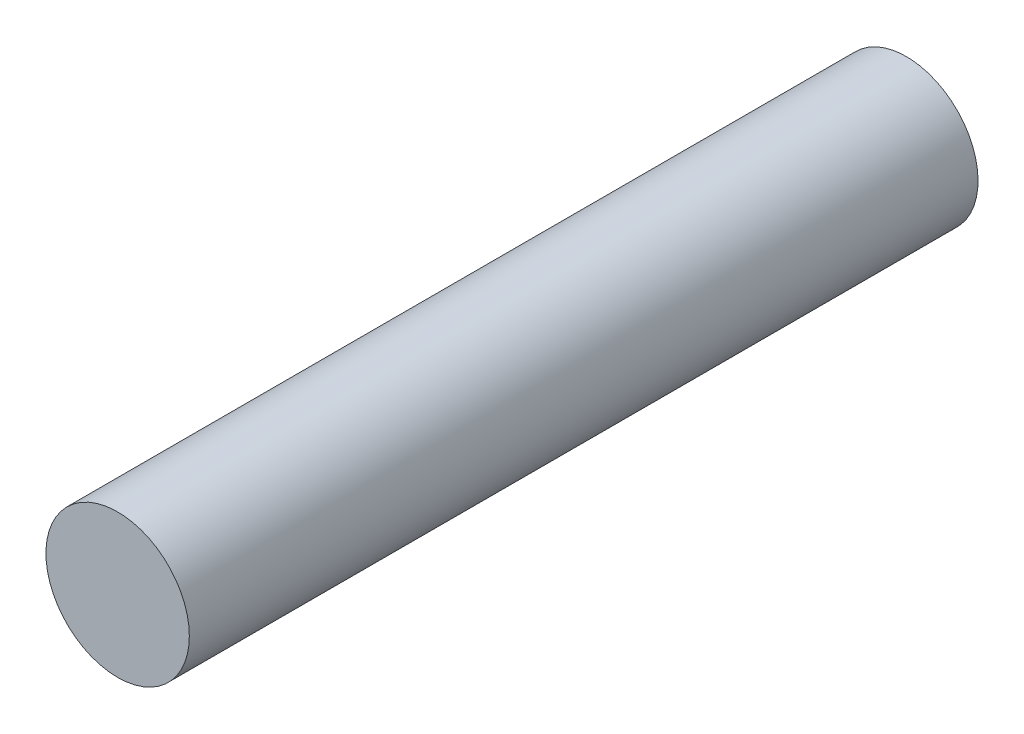
from build123d import *

# Parameters (mm, degrees)
SKETCH_1_R           = 3
EXTRUDE_1_DEPTH      = 25
EXTRUDE_1_DEPTH_BACK = 8


with BuildPart() as part:
    # ｽｹｯﾁ1 → ﾎﾞｽ - 押し出し1 (new body, two sides)
    with BuildSketch(Plane.XY) as extrude_1_sk:
        with Locations((8, 30)):
            Circle(SKETCH_1_R)
    extrude(amount=EXTRUDE_1_DEPTH)
    extrude(extrude_1_sk.sketch, amount=-EXTRUDE_1_DEPTH_BACK)


solid = part.part
